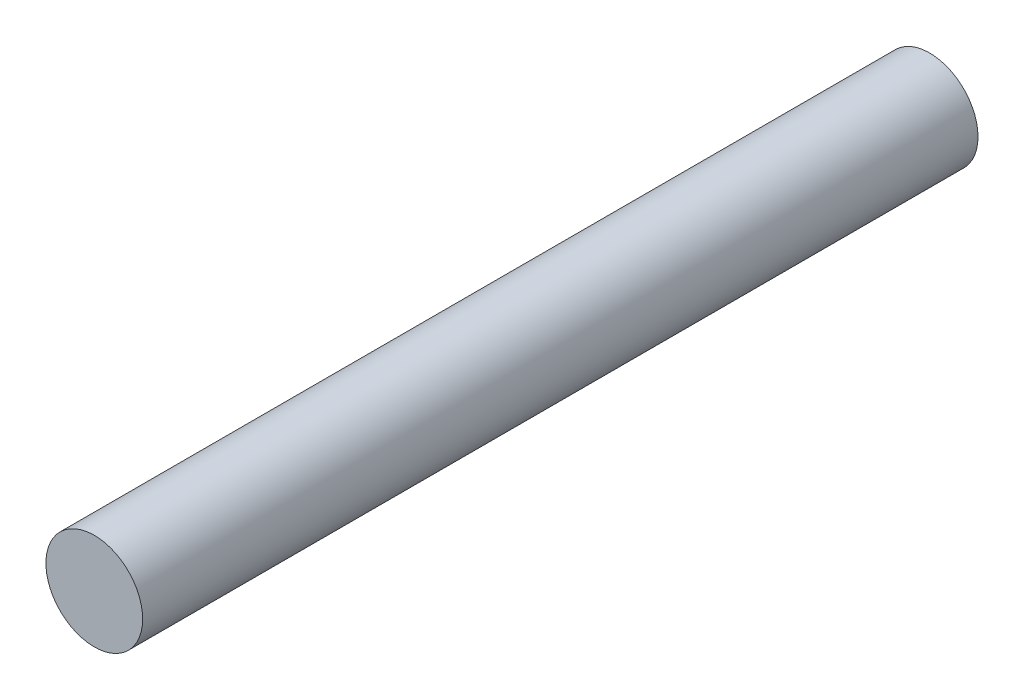
from build123d import *

# Parameters (mm, degrees)
SKETCH1_R           = 2.913907285
BOSS_EXTRUDE1_DEPTH = 50.331125828


with BuildPart() as part:
    # Sketch1 → Boss-Extrude1 (new body)
    with BuildSketch(Plane.XY):
        Circle(SKETCH1_R)
    extrude(amount=BOSS_EXTRUDE1_DEPTH)


solid = part.part
